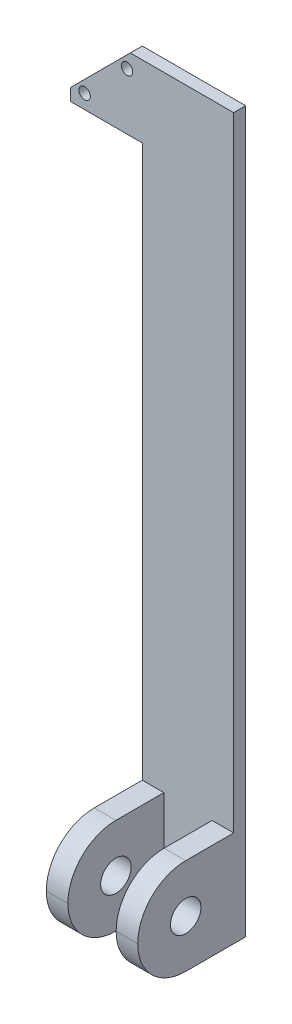
from build123d import *

# Parameters (mm, degrees)
SKETCH1_W           = 38.1
SKETCH1_H           = 300
BOSS_EXTRUDE1_DEPTH = 5
SKETCH2_W           = 9
SKETCH2_H           = 40
BOSS_EXTRUDE2_DEPTH = 40
CUT_EXTRUDE1_DEPTH  = 40


with BuildPart() as part:
    # Sketch1 → Boss-Extrude1 (new body)
    with BuildSketch(Plane.XY):
        with BuildLine():
            Line((-30, 275), (-30, 270))
            Line((-30, 270), (-25.725428583, 274.274571417))
            ThreePointArc((-25.725428583, 274.274571417), (-25.725428583, 277.642167462), (-22.357832538, 277.642167462))
            Line((-22.357832538, 277.642167462), (-8.047759053, 291.952240947))
            ThreePointArc((-8.047759053, 291.952240947), (-8.047759053, 295.319836992), (-4.680163008, 295.319836992))
            Line((-4.680163008, 295.319836992), (0, 300))
            Line((0, 300), (-5, 300))
            Line((-5, 300), (-30, 275))
        make_face()
        with BuildLine():
            Line((-25.725428583, 274.274571417), (-30, 270))
            Line((-30, 270), (0, 270))
            Line((0, 270), (0, 300))
            Line((0, 300), (-4.680163008, 295.319836992))
            ThreePointArc((-4.680163008, 295.319836992), (-4.163972894, 294.547303893), (-3.982711031, 293.636038969))
            ThreePointArc((-3.982711031, 293.636038969), (-5.452696107, 291.436050833), (-8.047759053, 291.952240947))
            Line((-8.047759053, 291.952240947), (-22.357832538, 277.642167462))
            ThreePointArc((-22.357832538, 277.642167462), (-21.841642424, 276.869634363), (-21.66038056, 275.95836944))
            ThreePointArc((-21.66038056, 275.95836944), (-23.130365637, 273.758381303), (-25.725428583, 274.274571417))
        make_face()
        with Locations((19.05, 150)):
            Rectangle(SKETCH1_W, SKETCH1_H)
    extrude(amount=BOSS_EXTRUDE1_DEPTH)

    # Sketch2 → Boss-Extrude2 (add)
    with BuildSketch(Plane.XY.offset(5)):
        with Locations((4.5, 20)):
            Rectangle(SKETCH2_W, SKETCH2_H)
        with Locations((33.6, 20)):
            Rectangle(SKETCH2_W, SKETCH2_H)
    extrude(amount=BOSS_EXTRUDE2_DEPTH)

    # Sketch3 → Cut-Extrude1 (cut)
    with BuildSketch(Plane(origin=(38.1, 0, 0), x_dir=(0, 0, -1), z_dir=(1, 0, 0))):
        with BuildLine():
            ThreePointArc((-18.65, 20), (-19.133364969, 22.430039796), (-20.509871939, 24.490128061))
            Line((-20.509871939, 24.490128061), (-29.490128061, 15.509871939))
            ThreePointArc((-29.490128061, 15.509871939), (-22.569960204, 14.133364969), (-18.65, 20))
        make_face()
        with BuildLine():
            Line((-29.490128061, 15.509871939), (-20.509871939, 24.490128061))
            ThreePointArc((-20.509871939, 24.490128061), (-29.490128061, 24.490128061), (-29.490128061, 15.509871939))
        make_face()
        with BuildLine():
            ThreePointArc((-45, 20.01), (-39.145064556, 34.145064556), (-25.01, 40))
            Line((-25.01, 40), (-45, 40))
            Line((-45, 40), (-45, 20.01))
        make_face()
        with BuildLine():
            Line((-45, 0), (-39.145064556, 5.854935444))
            ThreePointArc((-39.145064556, 5.854935444), (-43.478351855, 12.340158187), (-45, 19.99))
            Line((-45, 19.99), (-45, 0))
        make_face()
        with BuildLine():
            Line((-45, 0), (-25.01, 0))
            ThreePointArc((-25.01, 0), (-32.659841813, 1.521648145), (-39.145064556, 5.854935444))
            Line((-39.145064556, 5.854935444), (-45, 0))
        make_face()
    extrude(amount=-CUT_EXTRUDE1_DEPTH, mode=Mode.SUBTRACT)


solid = part.part
